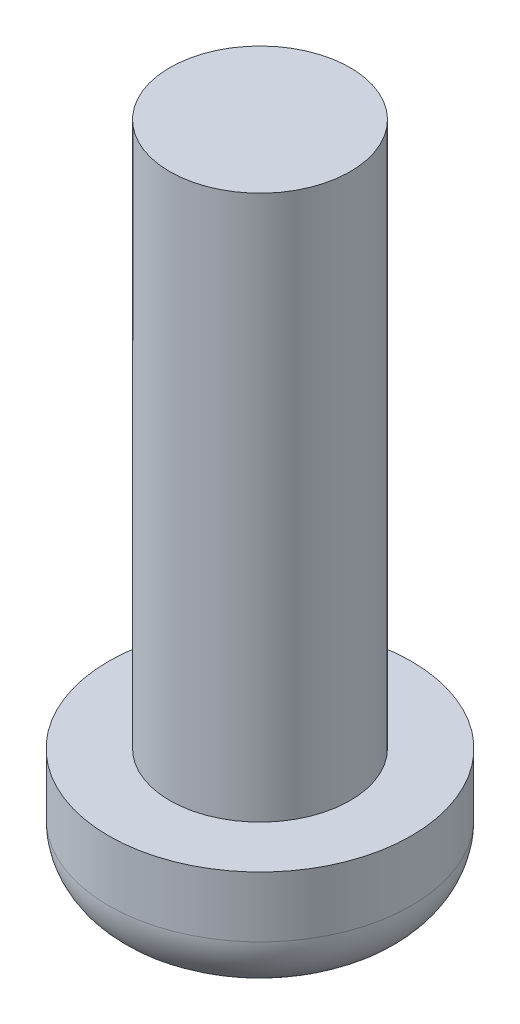
from build123d import *

# Parameters (mm, degrees)
SKETCH1_R           = 2.5
BOSS_EXTRUDE1_DEPTH = 2
SKETCH2_R           = 1.49
BOSS_EXTRUDE2_DEPTH = 9
FILLET3_R           = 1


with BuildPart() as part:
    # Sketch1 → Boss-Extrude1 (new body)
    with BuildSketch(Plane(origin=(0, 0, 0), x_dir=(1, 0, 0), z_dir=(0, 1, 0))):
        Circle(SKETCH1_R)
    extrude(amount=BOSS_EXTRUDE1_DEPTH)

    # Sketch2 → Boss-Extrude2 (add)
    with BuildSketch(Plane(origin=(0, 2, 0), x_dir=(1, 0, 0), z_dir=(0, 1, 0))):
        Circle(SKETCH2_R)
    extrude(amount=BOSS_EXTRUDE2_DEPTH)

    # Fillet3
    fillet3_edges = [part.edges().sort_by_distance(p)[0] for p in [
        (-2.5, 0, 0),
    ]]
    fillet(fillet3_edges, radius=FILLET3_R)


solid = part.part
